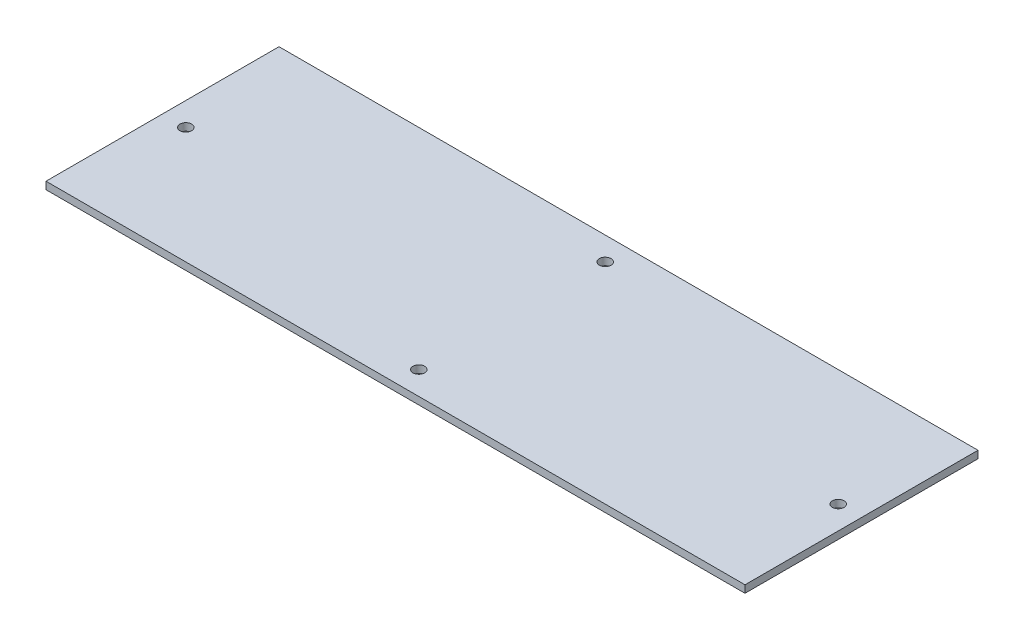
from build123d import *

# Parameters (mm, degrees)
SKETCH1_W           = 300
SKETCH1_H           = 100
SKETCH1_R           = 2.5
BOSS_EXTRUDE1_DEPTH = 3.175


with BuildPart() as part:
    # Sketch1 → Boss-Extrude1 (new body)
    with BuildSketch(Plane(origin=(0, 0, 0), x_dir=(1, 0, 0), z_dir=(0, 1, 0))):
        with Locations((150, 50)):
            Rectangle(SKETCH1_W, SKETCH1_H)
        with Locations((150, 10)):
            Circle(SKETCH1_R, mode=Mode.SUBTRACT)
        with Locations((10, 50)):
            Circle(SKETCH1_R, mode=Mode.SUBTRACT)
        with Locations((150, 90)):
            Circle(SKETCH1_R, mode=Mode.SUBTRACT)
        with Locations((290, 50)):
            Circle(SKETCH1_R, mode=Mode.SUBTRACT)
    extrude(amount=BOSS_EXTRUDE1_DEPTH)


solid = part.part
